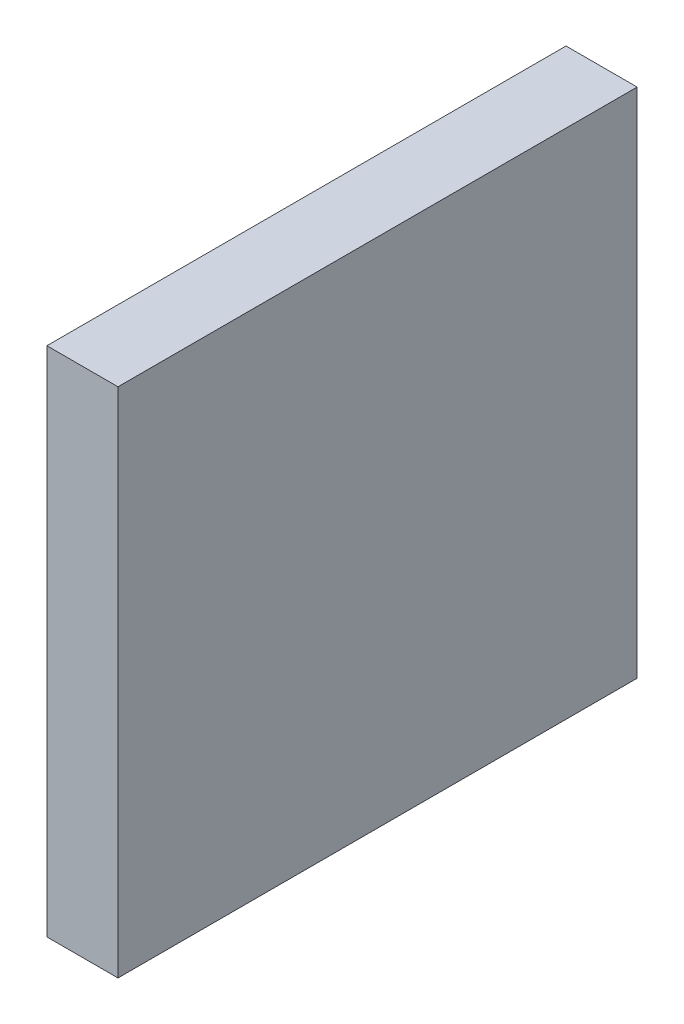
from build123d import *

# Parameters (mm, degrees)
SKETCH2_W           = 46.355
SKETCH2_H           = 45.72
BOSS_EXTRUDE1_DEPTH = 6.35


with BuildPart() as part:
    # Sketch2 → Boss-Extrude1 (new body)
    with BuildSketch(Plane(origin=(0, 0, 0), x_dir=(0, 0, -1), z_dir=(1, 0, 0))):
        with Locations((23.1775, 22.86)):
            Rectangle(SKETCH2_W, SKETCH2_H)
    extrude(amount=BOSS_EXTRUDE1_DEPTH)


solid = part.part
